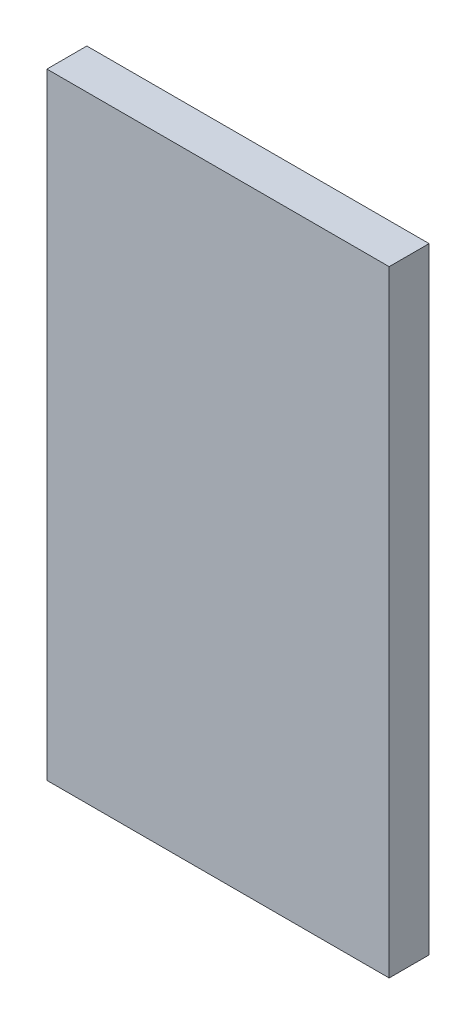
from build123d import *

# Parameters (mm, degrees)
RADIATOR_CROSS_SECTION_W = 381
RADIATOR_CROSS_SECTION_H = 685.8
RADIATOR_DEPTH           = 22.225


with BuildPart() as part:
    # Radiator Cross Section → Radiator (new body, symmetric)
    with BuildSketch(Plane.XY):
        Rectangle(RADIATOR_CROSS_SECTION_W, RADIATOR_CROSS_SECTION_H)
    extrude(amount=RADIATOR_DEPTH, both=True)


solid = part.part
